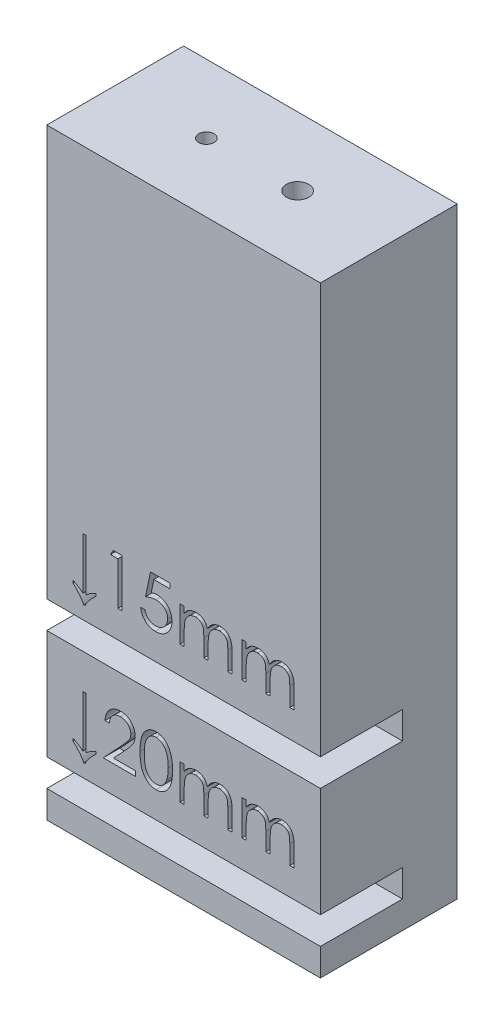
from build123d import *

# Parameters (mm, degrees)
SKETCH1_W               = 10
SKETCH1_H               = 5
BOSS_EXTRUDE1_DEPTH     = 22
SKETCH2_R               = 0.41
SKETCH2_R_2             = 0.28
CUT_EXTRUDE2_DEPTH      = 23
CUT_EXTRUDE2_DEPTH_BACK = 1
SKETCH3_W               = 10
SKETCH3_H               = 1
CUT_EXTRUDE3_DEPTH      = 3
CUT_EXTRUDE4_DEPTH      = 0.6


with BuildPart() as part:
    # Sketch1 → Boss-Extrude1 (new body)
    with BuildSketch(Plane(origin=(0, 0, 0), x_dir=(1, 0, 0), z_dir=(0, 1, 0))):
        Rectangle(SKETCH1_W, SKETCH1_H)
    extrude(amount=BOSS_EXTRUDE1_DEPTH)

    # Sketch2 → Cut-Extrude2 (cut, two sides)
    with BuildSketch(Plane(origin=(0, 0, 0), x_dir=(1, 0, 0), z_dir=(0, 1, 0))) as cut_extrude2_sk:
        with Locations((1.666666667, 0)):
            Circle(SKETCH2_R)
        with Locations((-1.666666667, 0)):
            Circle(SKETCH2_R_2)
    extrude(amount=CUT_EXTRUDE2_DEPTH, mode=Mode.SUBTRACT)
    extrude(cut_extrude2_sk.sketch, amount=-CUT_EXTRUDE2_DEPTH_BACK, mode=Mode.SUBTRACT)

    # Sketch3 → Cut-Extrude3 (cut)
    with BuildSketch(Plane.XY.offset(2.5)):
        with Locations((0, 6.5)):
            Rectangle(SKETCH3_W, SKETCH3_H)
        with Locations((0, 1.5)):
            Rectangle(SKETCH3_W, SKETCH3_H)
    extrude(amount=-CUT_EXTRUDE3_DEPTH, mode=Mode.SUBTRACT)

    # Sketch4 → Cut-Extrude4 (cut)
    with BuildSketch(Plane.XY.offset(2.5)):
        with BuildLine():
            Line((-4.038461538, 2.977213542), (-4.038461538, 3.067307692))
            add(Edge.make_bspline(
                [(-4.038461538, 3.067307692), (-4.006132303, 3.051316281), (-3.941926331, 3.019557285), (-3.849736919, 2.965774925), (-3.762023968, 2.907230434), (-3.706931473, 2.864323021), (-3.679487179, 2.842948718)],
                knots=[0, 0, 0, 0, 0.000108178, 0.000214842, 0.000319946, 0.000424275, 0.000424275, 0.000424275, 0.000424275], degree=3))
            Line((-3.679487179, 2.842948718), (-3.679487179, 4.727564103))
            Line((-3.679487179, 4.727564103), (-3.567307692, 4.727564103))
            Line((-3.567307692, 4.727564103), (-3.567307692, 2.842948718))
            add(Edge.make_bspline(
                [(-3.567307692, 2.842948718), (-3.556903118, 2.852658436), (-3.535381074, 2.872743156), (-3.499889313, 2.901252348), (-3.460721561, 2.929822277), (-3.417809068, 2.958054323), (-3.370796826, 2.985816265), (-3.32014112, 3.013355129), (-3.265630366, 3.040770457), (-3.22778201, 3.058299999), (-3.208333333, 3.067307692)],
                knots=[0, 0, 0, 0, 4.2682e-05, 8.8289e-05, 0.00013646, 0.000188089, 0.000242318, 0.000300204, 0.000361034, 0.000425331, 0.000425331, 0.000425331, 0.000425331], degree=3))
            Line((-3.208333333, 3.067307692), (-3.208333333, 2.976161859))
            add(Edge.make_bspline(
                [(-3.208333333, 2.976161859), (-3.231871552, 2.954486217), (-3.277719042, 2.912266631), (-3.341895447, 2.847679169), (-3.400124314, 2.784281697), (-3.45258414, 2.722198422), (-3.499003645, 2.661358246), (-3.539039146, 2.601413482), (-3.574014823, 2.543144471), (-3.59263083, 2.503303697), (-3.60166266, 2.483974359)],
                knots=[0, 0, 0, 0, 9.5985e-05, 0.000186959, 0.000273055, 0.000354163, 0.000430726, 0.000502481, 0.00057036, 0.000634328, 0.000634328, 0.000634328, 0.000634328], degree=3))
            Line((-3.60166266, 2.483974359), (-3.652844551, 2.483974359))
            add(Edge.make_bspline(
                [(-3.652844551, 2.483974359), (-3.660620924, 2.501989996), (-3.676857727, 2.539606039), (-3.708135379, 2.595674459), (-3.74634452, 2.653829832), (-3.790878345, 2.714679831), (-3.84303176, 2.777154909), (-3.901774183, 2.842137108), (-3.967368701, 2.909380469), (-4.014245247, 2.954107621), (-4.038461538, 2.977213542)],
                knots=[0, 0, 0, 0, 5.8838e-05, 0.000122851, 0.000192277, 0.000267511, 0.000348933, 0.000436302, 0.000530258, 0.000630666, 0.000630666, 0.000630666, 0.000630666], degree=3))
        make_face()
        with BuildLine():
            Line((-2.71474359, 4.211538462), (-2.871794872, 4.211538462))
            add(Edge.make_bspline(
                [(-2.871794872, 4.211538462), (-2.870771295, 4.232373905), (-2.868761018, 4.273294163), (-2.859346874, 4.332956116), (-2.845876435, 4.389983515), (-2.826830708, 4.443918472), (-2.803177569, 4.495237876), (-2.774812555, 4.543737884), (-2.74121563, 4.589233478), (-2.703112263, 4.6313029), (-2.661727944, 4.669896685), (-2.617074974, 4.703224307), (-2.57015246, 4.731383142), (-2.521102761, 4.754923763), (-2.469372479, 4.772593686), (-2.41543105, 4.785704506), (-2.359041482, 4.793592679), (-2.320621471, 4.794440572), (-2.301081731, 4.794871795)],
                knots=[0, 0, 0, 0, 6.2541e-05, 0.00012283, 0.000180902, 0.000238112, 0.000294107, 0.000350202, 0.000406364, 0.000463455, 0.000520264, 0.000575863, 0.000630273, 0.000684215, 0.00073876, 0.000793942, 0.00085056, 0.000909155, 0.000909155, 0.000909155, 0.000909155], degree=3))
            add(Edge.make_bspline(
                [(-2.301081731, 4.794871795), (-2.281892694, 4.794422567), (-2.244186921, 4.793539849), (-2.189155914, 4.785959335), (-2.136767267, 4.774086539), (-2.087123384, 4.757428831), (-2.040620351, 4.735036617), (-1.996908829, 4.708137848), (-1.955468424, 4.677027932), (-1.918165032, 4.640401025), (-1.883910992, 4.601299833), (-1.854359865, 4.559555881), (-1.829053283, 4.516441238), (-1.807959443, 4.471627138), (-1.792431374, 4.424691623), (-1.78064227, 4.376318022), (-1.773978563, 4.326005616), (-1.772955851, 4.291952339), (-1.772435897, 4.274639423)],
                knots=[0, 0, 0, 0, 5.7544e-05, 0.000113073, 0.000166307, 0.000218522, 0.000269796, 0.000320781, 0.000372314, 0.000424875, 0.000477311, 0.000528087, 0.000578051, 0.000627142, 0.000676363, 0.000726104, 0.000776327, 0.000828268, 0.000828268, 0.000828268, 0.000828268], degree=3))
            add(Edge.make_bspline(
                [(-1.772435897, 4.274639423), (-1.773282529, 4.250265506), (-1.774960935, 4.201945399), (-1.789318123, 4.130937968), (-1.811741378, 4.062141258), (-1.838740057, 4.006772607), (-1.865976279, 3.96215586), (-1.890520033, 3.925421508), (-1.919252438, 3.885868773), (-1.952591687, 3.843630105), (-1.989848123, 3.798374652), (-2.031359205, 3.750129755), (-2.077420946, 3.69939387), (-2.109750196, 3.664741069), (-2.126502404, 3.646784856)],
                knots=[0, 0, 0, 0, 7.3059e-05, 0.000144836, 0.00021645, 0.00028967, 0.000328989, 0.000373228, 0.000422172, 0.00047561, 0.000534634, 0.00059802, 0.000666524, 0.000740196, 0.000740196, 0.000740196, 0.000740196], degree=3))
            Line((-2.126502404, 3.646784856), (-2.564352965, 3.179487179))
            Line((-2.564352965, 3.179487179), (-1.75, 3.179487179))
            Line((-1.75, 3.179487179), (-1.75, 3))
            Line((-1.75, 3), (-2.939102564, 3))
            Line((-2.939102564, 3), (-2.260416667, 3.724258814))
            add(Edge.make_bspline(
                [(-2.260416667, 3.724258814), (-2.243892723, 3.741507967), (-2.21215361, 3.774640061), (-2.167262321, 3.823011541), (-2.126942827, 3.867886311), (-2.090934131, 3.909179585), (-2.060017378, 3.947495369), (-2.032581262, 3.981592721), (-2.010598467, 4.012969946), (-1.986740769, 4.049340253), (-1.963633778, 4.093746412), (-1.9437776, 4.148013256), (-1.931670176, 4.203876883), (-1.930217758, 4.241627901), (-1.929487179, 4.260616987)],
                knots=[0, 0, 0, 0, 7.1659e-05, 0.000137643, 0.000197965, 0.000252644, 0.000301974, 0.000345665, 0.000383891, 0.000416855, 0.000476124, 0.000533568, 0.000589809, 0.000646731, 0.000646731, 0.000646731, 0.000646731], degree=3))
            add(Edge.make_bspline(
                [(-1.929487179, 4.260616987), (-1.929805051, 4.272557686), (-1.930431514, 4.296090512), (-1.935960362, 4.330593391), (-1.944315615, 4.363875798), (-1.956288244, 4.396040108), (-1.972091614, 4.426762934), (-1.991328304, 4.456081674), (-2.013523336, 4.484426156), (-2.039198971, 4.511002805), (-2.067404731, 4.535343408), (-2.097201856, 4.556905451), (-2.128726908, 4.574925006), (-2.161846969, 4.589696755), (-2.196469703, 4.601284445), (-2.232662076, 4.609313735), (-2.270324084, 4.614354977), (-2.296040832, 4.615037063), (-2.309144631, 4.615384615)],
                knots=[0, 0, 0, 0, 3.58e-05, 7.0555e-05, 0.000104565, 0.00013862, 0.000173269, 0.000207981, 0.000243678, 0.000281116, 0.000318646, 0.000355323, 0.000391282, 0.000427375, 0.000463957, 0.000500612, 0.000538442, 0.000577744, 0.000577744, 0.000577744, 0.000577744], degree=3))
            add(Edge.make_bspline(
                [(-2.309144631, 4.615384615), (-2.322830048, 4.615027099), (-2.349705946, 4.614324997), (-2.389165462, 4.609413665), (-2.426808351, 4.600940744), (-2.462729303, 4.589352407), (-2.496989096, 4.574623133), (-2.529421118, 4.55627726), (-2.559952562, 4.534385514), (-2.588640824, 4.509565236), (-2.615072813, 4.481931435), (-2.638296251, 4.451126454), (-2.658588258, 4.417712746), (-2.676292875, 4.381780471), (-2.69067072, 4.343003581), (-2.701657295, 4.301519728), (-2.710350719, 4.257509037), (-2.713254979, 4.227116495), (-2.71474359, 4.211538462)],
                knots=[0, 0, 0, 0, 4.1053e-05, 8.0621e-05, 0.000119063, 0.000156645, 0.000193701, 0.000230747, 0.000268198, 0.000306223, 0.00034441, 0.000382691, 0.000421711, 0.000461533, 0.000502686, 0.000545547, 0.000590167, 0.000637087, 0.000637087, 0.000637087, 0.000637087], degree=3))
        make_face()
        with BuildLine():
            add(Edge.make_bspline(
                [(-1.592948718, 3.874298878), (-1.592784709, 3.902347572), (-1.592466119, 3.956832564), (-1.588921908, 4.036224885), (-1.583034237, 4.11070503), (-1.574965551, 4.180276563), (-1.565146561, 4.244957445), (-1.552038817, 4.304574824), (-1.537132416, 4.359404627), (-1.519856193, 4.409625651), (-1.500362299, 4.455914503), (-1.479145168, 4.499127103), (-1.455362771, 4.539198069), (-1.430374315, 4.576766965), (-1.403168279, 4.611218812), (-1.374518884, 4.643040143), (-1.343307945, 4.671495519), (-1.310596441, 4.69741867), (-1.276088209, 4.720143406), (-1.240766876, 4.740159775), (-1.204389323, 4.757259709), (-1.166856232, 4.770704926), (-1.128504953, 4.78181035), (-1.089201419, 4.789404824), (-1.048880737, 4.794183278), (-1.02166502, 4.794640112), (-1.00786258, 4.794871795)],
                knots=[0, 0, 0, 0, 8.4141e-05, 0.000163445, 0.000238352, 0.00030823, 0.00037353, 0.00043452, 0.000491247, 0.000543907, 0.000593714, 0.000641844, 0.000688199, 0.000733411, 0.000777102, 0.000819784, 0.000861712, 0.000903651, 0.000944876, 0.000985532, 0.001025368, 0.001065292, 0.001105018, 0.001145031, 0.001185254, 0.001226644, 0.001226644, 0.001226644, 0.001226644], degree=3))
            add(Edge.make_bspline(
                [(-1.00786258, 4.794871795), (-0.993944841, 4.794627887), (-0.966266836, 4.794142832), (-0.925346649, 4.789480861), (-0.885371808, 4.781745299), (-0.846512739, 4.770784812), (-0.808450245, 4.757186973), (-0.771482042, 4.740143415), (-0.735378501, 4.720303981), (-0.700713357, 4.696992043), (-0.667106049, 4.671000904), (-0.635382068, 4.64161957), (-0.605538525, 4.60914471), (-0.577200872, 4.573923778), (-0.551173074, 4.535281236), (-0.526386357, 4.493889181), (-0.504200339, 4.449023749), (-0.482833002, 4.401433515), (-0.464389509, 4.349801685), (-0.447756386, 4.294419305), (-0.434316902, 4.234632212), (-0.423122265, 4.170754089), (-0.414449817, 4.102550347), (-0.408133496, 4.03016719), (-0.404796954, 3.953556994), (-0.404168603, 3.90117807), (-0.403846154, 3.874298878)],
                knots=[0, 0, 0, 0, 4.174e-05, 8.3008e-05, 0.000123365, 0.000163767, 0.00020402, 0.000244493, 0.000285761, 0.000327472, 0.000369686, 0.000413101, 0.000457011, 0.000501904, 0.000548576, 0.000596673, 0.000646528, 0.000698638, 0.000753088, 0.000810875, 0.000872019, 0.0009368, 0.001005371, 0.001078211, 0.001154713, 0.001235355, 0.001235355, 0.001235355, 0.001235355], degree=3))
            add(Edge.make_bspline(
                [(-0.403846154, 3.874298878), (-0.404171946, 3.847536924), (-0.404806739, 3.795392348), (-0.408096092, 3.719126861), (-0.414575408, 3.647127839), (-0.422680402, 3.579222608), (-0.433905884, 3.515693798), (-0.447708467, 3.456321574), (-0.463033628, 3.400849538), (-0.481951025, 3.349732132), (-0.50265638, 3.302256271), (-0.525183979, 3.257922697), (-0.549318892, 3.216339551), (-0.575613264, 3.177839677), (-0.603639971, 3.142150349), (-0.633998865, 3.109901537), (-0.665834158, 3.080316201), (-0.699540366, 3.053990388), (-0.734746141, 3.030947985), (-0.77072568, 3.01034106), (-0.808117371, 2.993724712), (-0.846073848, 2.979457192), (-0.885138031, 2.968556966), (-0.925261226, 2.961020038), (-0.966239344, 2.955734114), (-0.993940127, 2.955330874), (-1.00786258, 2.955128205)],
                knots=[0, 0, 0, 0, 8.0291e-05, 0.000156443, 0.000228934, 0.000297113, 0.000361549, 0.000422351, 0.000479942, 0.000534062, 0.00058571, 0.000635252, 0.000683172, 0.000729844, 0.000775012, 0.00081916, 0.000862575, 0.000905281, 0.000947284, 0.000988723, 0.001029515, 0.001069889, 0.00111029, 0.001150991, 0.0011923, 0.00123404, 0.00123404, 0.00123404, 0.00123404], degree=3))
            add(Edge.make_bspline(
                [(-1.00786258, 2.955128205), (-1.021664637, 2.955361383), (-1.0488796, 2.955821164), (-1.089205812, 2.96057803), (-1.128347034, 2.968225781), (-1.166496411, 2.978934083), (-1.203849669, 2.992041501), (-1.239897812, 3.009118343), (-1.275041654, 3.028785378), (-1.309187432, 3.051183088), (-1.341693512, 3.07684393), (-1.372742815, 3.105226074), (-1.401555324, 3.13703778), (-1.428372372, 3.171776741), (-1.453859416, 3.209123363), (-1.477304103, 3.249587549), (-1.49898953, 3.293008854), (-1.518811275, 3.33966781), (-1.536385607, 3.390245274), (-1.551909461, 3.445319863), (-1.56416654, 3.505377681), (-1.574658018, 3.569936365), (-1.583120209, 3.63927333), (-1.588897372, 3.713426219), (-1.592468029, 3.792348823), (-1.592785564, 3.84648371), (-1.592948718, 3.874298878)],
                knots=[0, 0, 0, 0, 4.139e-05, 8.1613e-05, 0.000121626, 0.00016092, 0.000200395, 0.000240231, 0.00028041, 0.000321149, 0.000362595, 0.000404524, 0.000447206, 0.000491173, 0.000536094, 0.000582751, 0.000631352, 0.000681618, 0.000734724, 0.000791883, 0.000853143, 0.000918498, 0.000988069, 0.001062626, 0.00114158, 0.00122502, 0.00122502, 0.00122502, 0.00122502], degree=3))
        make_face()
        with BuildLine():
            add(Edge.make_bspline(
                [(-1.435897436, 3.875), (-1.435837712, 3.851625651), (-1.435721801, 3.806260628), (-1.4326937, 3.740338998), (-1.428568584, 3.678853833), (-1.423247936, 3.621727065), (-1.415346462, 3.569152059), (-1.406493068, 3.520767217), (-1.395719023, 3.476828599), (-1.382971514, 3.437034693), (-1.368451965, 3.400710159), (-1.352599034, 3.366909552), (-1.335568672, 3.335233583), (-1.316509097, 3.305966779), (-1.295751565, 3.279013697), (-1.273764936, 3.253897281), (-1.249728644, 3.23149879), (-1.216476772, 3.204635363), (-1.172578535, 3.176875796), (-1.117268308, 3.152702751), (-1.060434082, 3.137511523), (-1.021858457, 3.135579645), (-1.002604167, 3.134615385)],
                knots=[0, 0, 0, 0, 7.0116e-05, 0.000136081, 0.000197923, 0.00025499, 0.000308137, 0.000357365, 0.000402513, 0.000443754, 0.000482617, 0.000519785, 0.000555708, 0.000590421, 0.000624427, 0.000657703, 0.000690439, 0.00072285, 0.000785873, 0.00084553, 0.000903432, 0.000961133, 0.000961133, 0.000961133, 0.000961133], degree=3))
            add(Edge.make_bspline(
                [(-1.002604167, 3.134615385), (-0.983225331, 3.135414275), (-0.944507669, 3.137010406), (-0.887940772, 3.152409775), (-0.833025637, 3.175644545), (-0.789989666, 3.203118298), (-0.757248395, 3.229282462), (-0.7337899, 3.251589786), (-0.712258875, 3.27656772), (-0.691837838, 3.303517368), (-0.6731083, 3.33295361), (-0.656076731, 3.364734898), (-0.640535058, 3.398949487), (-0.631680535, 3.422834356), (-0.627153446, 3.435046074)],
                knots=[0, 0, 0, 0, 5.8022e-05, 0.000115924, 0.000174659, 0.000236419, 0.000268337, 0.000300323, 0.000333367, 0.000367161, 0.000401684, 0.000437915, 0.000475255, 0.000514317, 0.000514317, 0.000514317, 0.000514317], degree=3))
            add(Edge.make_bspline(
                [(-0.627153446, 3.435046074), (-0.621877562, 3.450660943), (-0.611165255, 3.482365826), (-0.597359368, 3.531547652), (-0.586486668, 3.583149034), (-0.576704985, 3.636861592), (-0.570028457, 3.693081442), (-0.56465455, 3.751634634), (-0.561489207, 3.812565316), (-0.561096831, 3.853962811), (-0.560897436, 3.875)],
                knots=[0, 0, 0, 0, 4.9443e-05, 0.00010039, 0.000153129, 0.000207594, 0.00026412, 0.000322899, 0.000383979, 0.000447088, 0.000447088, 0.000447088, 0.000447088], degree=3))
            add(Edge.make_bspline(
                [(-0.560897436, 3.875), (-0.561172531, 3.896033786), (-0.561710674, 3.937180369), (-0.563767668, 3.997439459), (-0.569079455, 4.054673339), (-0.574979015, 4.109128576), (-0.583677625, 4.160503727), (-0.593056529, 4.20922888), (-0.605657135, 4.254700392), (-0.619117023, 4.297630183), (-0.63452222, 4.33753051), (-0.651480087, 4.374587403), (-0.669590967, 4.408979766), (-0.689262087, 4.440613237), (-0.710259929, 4.469629508), (-0.733138703, 4.495446805), (-0.75699089, 4.518865289), (-0.790399482, 4.545596574), (-0.834136627, 4.572852422), (-0.888559451, 4.597935302), (-0.945194773, 4.612339448), (-0.9834815, 4.614370291), (-1.002604167, 4.615384615)],
                knots=[0, 0, 0, 0, 6.311e-05, 0.000123456, 0.000180808, 0.00023551, 0.000287725, 0.000337088, 0.000384284, 0.000429184, 0.000472022, 0.000512494, 0.000551386, 0.000588545, 0.000624165, 0.000658693, 0.000691913, 0.000724324, 0.000786864, 0.000846021, 0.000903497, 0.000960849, 0.000960849, 0.000960849, 0.000960849], degree=3))
            add(Edge.make_bspline(
                [(-1.002604167, 4.615384615), (-1.021959463, 4.614368892), (-1.060705316, 4.612335595), (-1.117929293, 4.597988968), (-1.172781469, 4.572982485), (-1.216402956, 4.545506299), (-1.249834849, 4.519337143), (-1.273376196, 4.496643916), (-1.295449282, 4.471820789), (-1.315783132, 4.444619832), (-1.334827774, 4.415387148), (-1.35231828, 4.383892766), (-1.368076945, 4.349977084), (-1.382619213, 4.313668866), (-1.395405607, 4.273878394), (-1.405952589, 4.229993897), (-1.415696115, 4.181762951), (-1.42259375, 4.128903197), (-1.428725627, 4.07176212), (-1.432666301, 4.010123461), (-1.43573193, 3.944091271), (-1.435841162, 3.898491692), (-1.435897436, 3.875)],
                knots=[0, 0, 0, 0, 5.805e-05, 0.000116207, 0.000175684, 0.000238224, 0.000270416, 0.000302898, 0.000336173, 0.000369967, 0.00040468, 0.000440772, 0.00047794, 0.000516803, 0.000558045, 0.000603192, 0.000652143, 0.000705587, 0.000763038, 0.000824531, 0.000890846, 0.000961312, 0.000961312, 0.000961312, 0.000961312], degree=3))
        make_face(mode=Mode.SUBTRACT)
        with BuildLine():
            Line((-0.134615385, 4.278846154), (0.022435897, 4.278846154))
            Line((0.022435897, 4.278846154), (0.022435897, 4.056590545))
            add(Edge.make_bspline(
                [(0.022435897, 4.056590545), (0.036577872, 4.076034346), (0.063675252, 4.113290532), (0.108108078, 4.162385674), (0.152496135, 4.204049752), (0.184462826, 4.225921188), (0.199819712, 4.236428285)],
                knots=[0, 0, 0, 0, 7.2076e-05, 0.000138104, 0.000198402, 0.000254151, 0.000254151, 0.000254151, 0.000254151], degree=3))
            add(Edge.make_bspline(
                [(0.199819712, 4.236428285), (0.220752043, 4.246430968), (0.262250992, 4.266261575), (0.327960605, 4.286378354), (0.39519794, 4.298740905), (0.440602047, 4.300431591), (0.463441506, 4.301282051)],
                knots=[0, 0, 0, 0, 6.9515e-05, 0.000137816, 0.000205481, 0.00027397, 0.00027397, 0.00027397, 0.00027397], degree=3))
            add(Edge.make_bspline(
                [(0.463441506, 4.301282051), (0.478888005, 4.300759406), (0.509455794, 4.299725119), (0.554747839, 4.292995101), (0.598677145, 4.281362015), (0.64098416, 4.265158353), (0.680844499, 4.245535009), (0.717389098, 4.222510155), (0.750201202, 4.196661618), (0.779264228, 4.166822151), (0.805398741, 4.132153852), (0.829438164, 4.091721727), (0.85165077, 4.044617897), (0.863961425, 4.010434626), (0.870442708, 3.992437901)],
                knots=[0, 0, 0, 0, 4.6339e-05, 9.1703e-05, 0.000137024, 0.000182404, 0.000227399, 0.000270095, 0.000311759, 0.000352415, 0.000394693, 0.000441708, 0.000493299, 0.000550659, 0.000550659, 0.000550659, 0.000550659], degree=3))
            add(Edge.make_bspline(
                [(0.870442708, 3.992437901), (0.877298334, 4.00480011), (0.890789243, 4.029127203), (0.913442061, 4.063556334), (0.937175959, 4.09575973), (0.962193206, 4.125762942), (0.988405499, 4.153417807), (1.015936199, 4.178815758), (1.04462859, 4.202065865), (1.08452471, 4.229227445), (1.136431014, 4.258078035), (1.201875071, 4.283092257), (1.269950157, 4.298550321), (1.316159006, 4.300365458), (1.339493189, 4.301282051)],
                knots=[0, 0, 0, 0, 4.2395e-05, 8.3427e-05, 0.000123532, 0.000162357, 0.000200544, 0.000237757, 0.000274657, 0.000311218, 0.00038245, 0.000452244, 0.0005208, 0.000590734, 0.000590734, 0.000590734, 0.000590734], degree=3))
            add(Edge.make_bspline(
                [(1.339493189, 4.301282051), (1.360933921, 4.300473441), (1.402895514, 4.298890912), (1.463984146, 4.286464175), (1.520955049, 4.265125352), (1.573693587, 4.236008533), (1.621273494, 4.199418942), (1.662631649, 4.155884523), (1.69751683, 4.105713211), (1.72030615, 4.058517217), (1.735763782, 4.01684955), (1.745294399, 3.981346405), (1.753714247, 3.942270628), (1.760704869, 3.899575498), (1.765814146, 3.853110193), (1.769599503, 3.802950756), (1.77216154, 3.7490582), (1.772342576, 3.71187545), (1.772435897, 3.692708333)],
                knots=[0, 0, 0, 0, 6.429e-05, 0.000125823, 0.000186055, 0.000246152, 0.000305893, 0.000365404, 0.000425599, 0.000488468, 0.000522072, 0.000558814, 0.000598626, 0.000641965, 0.000688537, 0.000738815, 0.000792857, 0.000850354, 0.000850354, 0.000850354, 0.000850354], degree=3))
            Line((1.772435897, 3.692708333), (1.772435897, 3))
            Line((1.772435897, 3), (1.615384615, 3))
            Line((1.615384615, 3), (1.615384615, 3.693409455))
            add(Edge.make_bspline(
                [(1.615384615, 3.693409455), (1.615345674, 3.709769742), (1.615270834, 3.741211726), (1.613924018, 3.786337951), (1.611386361, 3.82747213), (1.608419042, 3.864558174), (1.604297137, 3.897682568), (1.598974172, 3.926778777), (1.593335332, 3.952075683), (1.583967336, 3.980118707), (1.56899339, 4.011053812), (1.54618465, 4.0444156), (1.517449597, 4.073456), (1.484269519, 4.098665158), (1.446495296, 4.119161979), (1.404862935, 4.133799984), (1.359630909, 4.142861423), (1.328319515, 4.143764431), (1.312149439, 4.144230769)],
                knots=[0, 0, 0, 0, 4.908e-05, 9.4324e-05, 0.000135413, 0.000172706, 0.000205926, 0.000235494, 0.000261428, 0.0002836, 0.000324053, 0.000364117, 0.000404277, 0.000446064, 0.000488731, 0.000532639, 0.000578015, 0.000626473, 0.000626473, 0.000626473, 0.000626473], degree=3))
            add(Edge.make_bspline(
                [(1.312149439, 4.144230769), (1.292314462, 4.143522691), (1.253113006, 4.142123258), (1.195890263, 4.127836321), (1.140904755, 4.106296196), (1.089797188, 4.075079967), (1.042783293, 4.037675786), (1.002333504, 3.993200988), (0.968917411, 3.942886024), (0.946290423, 3.896312673), (0.931995773, 3.854477951), (0.922557315, 3.817929265), (0.915215619, 3.776388481), (0.908330355, 3.730134736), (0.903836491, 3.678849646), (0.899752304, 3.622770445), (0.897841873, 3.561728465), (0.897574644, 3.519415121), (0.897435897, 3.497445913)],
                knots=[0, 0, 0, 0, 5.9394e-05, 0.000117385, 0.000175908, 0.000235968, 0.000296301, 0.000355608, 0.000415501, 0.000476964, 0.000510334, 0.000548001, 0.00059008, 0.000636831, 0.000688247, 0.00074447, 0.000805503, 0.000871413, 0.000871413, 0.000871413, 0.000871413], degree=3))
            Line((0.897435897, 3.497445913), (0.897435897, 3))
            Line((0.897435897, 3), (0.740384615, 3))
            Line((0.740384615, 3), (0.740384615, 3.650290465))
            add(Edge.make_bspline(
                [(0.740384615, 3.650290465), (0.7403449, 3.668637124), (0.740268491, 3.703934253), (0.738930333, 3.75455109), (0.736387022, 3.80059163), (0.733446748, 3.842002362), (0.729216658, 3.878708027), (0.724411777, 3.910905406), (0.718737472, 3.938513781), (0.70934253, 3.968795474), (0.694985296, 4.002155935), (0.671891165, 4.037726446), (0.643087374, 4.068860495), (0.609301936, 4.095439869), (0.571299095, 4.117410609), (0.529307395, 4.133240485), (0.483704939, 4.14245263), (0.452266086, 4.143626878), (0.436097756, 4.144230769)],
                knots=[0, 0, 0, 0, 5.5039e-05, 0.00010589, 0.000151879, 0.000193365, 0.000230414, 0.00026269, 0.000291018, 0.000314859, 0.000357715, 0.000399526, 0.000441454, 0.000484378, 0.000528033, 0.000572633, 0.000618421, 0.000666901, 0.000666901, 0.000666901, 0.000666901], degree=3))
            add(Edge.make_bspline(
                [(0.436097756, 4.144230769), (0.417089651, 4.143465539), (0.379207171, 4.141940463), (0.323556186, 4.128213326), (0.269813344, 4.106711289), (0.218835995, 4.076881379), (0.171998921, 4.03993184), (0.130994787, 3.996474392), (0.096523524, 3.947049875), (0.073657617, 3.900967617), (0.05890838, 3.860180979), (0.049110713, 3.825505506), (0.0406909, 3.787005382), (0.034433889, 3.744561826), (0.028393681, 3.698451279), (0.025478526, 3.648444034), (0.022642745, 3.59458299), (0.022506538, 3.557396718), (0.022435897, 3.538110978)],
                knots=[0, 0, 0, 0, 5.6946e-05, 0.000113492, 0.000170908, 0.000230132, 0.000290028, 0.000349298, 0.000408718, 0.000470174, 0.000502999, 0.000538729, 0.000578198, 0.000621136, 0.0006674, 0.000717653, 0.000771345, 0.000829192, 0.000829192, 0.000829192, 0.000829192], degree=3))
            Line((0.022435897, 3.538110978), (0.022435897, 3))
            Line((0.022435897, 3), (-0.134615385, 3))
            Line((-0.134615385, 3), (-0.134615385, 4.278846154))
        make_face()
        with BuildLine():
            Line((2.131410256, 4.278846154), (2.288461538, 4.278846154))
            Line((2.288461538, 4.278846154), (2.288461538, 4.056590545))
            add(Edge.make_bspline(
                [(2.288461538, 4.056590545), (2.302603513, 4.076034346), (2.329700893, 4.113290532), (2.374133719, 4.162385674), (2.418521776, 4.204049752), (2.450488467, 4.225921188), (2.465845353, 4.236428285)],
                knots=[0, 0, 0, 0, 7.2076e-05, 0.000138104, 0.000198402, 0.000254151, 0.000254151, 0.000254151, 0.000254151], degree=3))
            add(Edge.make_bspline(
                [(2.465845353, 4.236428285), (2.486777684, 4.246430968), (2.528276634, 4.266261575), (2.593986246, 4.286378354), (2.661223581, 4.298740905), (2.706627688, 4.300431591), (2.729467147, 4.301282051)],
                knots=[0, 0, 0, 0, 6.9515e-05, 0.000137816, 0.000205481, 0.00027397, 0.00027397, 0.00027397, 0.00027397], degree=3))
            add(Edge.make_bspline(
                [(2.729467147, 4.301282051), (2.744913646, 4.300759406), (2.775481435, 4.299725119), (2.82077348, 4.292995101), (2.864702786, 4.281362015), (2.907009801, 4.265158353), (2.946870141, 4.245535009), (2.983414739, 4.222510155), (3.016226843, 4.196661618), (3.045289869, 4.166822151), (3.071424382, 4.132153852), (3.095463805, 4.091721727), (3.117676411, 4.044617897), (3.129987066, 4.010434626), (3.136468349, 3.992437901)],
                knots=[0, 0, 0, 0, 4.6339e-05, 9.1703e-05, 0.000137024, 0.000182404, 0.000227399, 0.000270095, 0.000311759, 0.000352415, 0.000394693, 0.000441708, 0.000493299, 0.000550659, 0.000550659, 0.000550659, 0.000550659], degree=3))
            add(Edge.make_bspline(
                [(3.136468349, 3.992437901), (3.143323975, 4.00480011), (3.156814884, 4.029127203), (3.179467702, 4.063556334), (3.2032016, 4.09575973), (3.228218847, 4.125762942), (3.25443114, 4.153417807), (3.28196184, 4.178815758), (3.310654231, 4.202065865), (3.350550351, 4.229227445), (3.402456655, 4.258078035), (3.467900712, 4.283092257), (3.535975798, 4.298550321), (3.582184647, 4.300365458), (3.60551883, 4.301282051)],
                knots=[0, 0, 0, 0, 4.2395e-05, 8.3427e-05, 0.000123532, 0.000162357, 0.000200544, 0.000237757, 0.000274657, 0.000311218, 0.00038245, 0.000452244, 0.0005208, 0.000590734, 0.000590734, 0.000590734, 0.000590734], degree=3))
            add(Edge.make_bspline(
                [(3.60551883, 4.301282051), (3.626959562, 4.300473441), (3.668921155, 4.298890912), (3.730009788, 4.286464175), (3.78698069, 4.265125352), (3.839719228, 4.236008533), (3.887299135, 4.199418942), (3.92865729, 4.155884523), (3.963542471, 4.105713211), (3.986331791, 4.058517217), (4.001789423, 4.01684955), (4.01132004, 3.981346405), (4.019739888, 3.942270628), (4.026730511, 3.899575498), (4.031839787, 3.853110193), (4.035625144, 3.802950756), (4.038187181, 3.7490582), (4.038368217, 3.71187545), (4.038461538, 3.692708333)],
                knots=[0, 0, 0, 0, 6.429e-05, 0.000125823, 0.000186055, 0.000246152, 0.000305893, 0.000365404, 0.000425599, 0.000488468, 0.000522072, 0.000558814, 0.000598626, 0.000641965, 0.000688537, 0.000738815, 0.000792857, 0.000850354, 0.000850354, 0.000850354, 0.000850354], degree=3))
            Line((4.038461538, 3.692708333), (4.038461538, 3))
            Line((4.038461538, 3), (3.881410256, 3))
            Line((3.881410256, 3), (3.881410256, 3.693409455))
            add(Edge.make_bspline(
                [(3.881410256, 3.693409455), (3.881371315, 3.709769742), (3.881296475, 3.741211726), (3.87994966, 3.786337951), (3.877412002, 3.82747213), (3.874444683, 3.864558174), (3.870322778, 3.897682568), (3.864999813, 3.926778777), (3.859360973, 3.952075683), (3.849992977, 3.980118707), (3.835019031, 4.011053812), (3.812210291, 4.0444156), (3.783475238, 4.073456), (3.75029516, 4.098665158), (3.712520937, 4.119161979), (3.670888576, 4.133799984), (3.62565655, 4.142861423), (3.594345156, 4.143764431), (3.57817508, 4.144230769)],
                knots=[0, 0, 0, 0, 4.908e-05, 9.4324e-05, 0.000135413, 0.000172706, 0.000205926, 0.000235494, 0.000261428, 0.0002836, 0.000324053, 0.000364117, 0.000404277, 0.000446064, 0.000488731, 0.000532639, 0.000578015, 0.000626473, 0.000626473, 0.000626473, 0.000626473], degree=3))
            add(Edge.make_bspline(
                [(3.57817508, 4.144230769), (3.558340103, 4.143522691), (3.519138647, 4.142123258), (3.461915904, 4.127836321), (3.406930396, 4.106296196), (3.355822829, 4.075079967), (3.308808934, 4.037675786), (3.268359145, 3.993200988), (3.234943052, 3.942886024), (3.212316064, 3.896312673), (3.198021414, 3.854477951), (3.188582956, 3.817929265), (3.18124126, 3.776388481), (3.174355996, 3.730134736), (3.169862132, 3.678849646), (3.165777945, 3.622770445), (3.163867514, 3.561728465), (3.163600285, 3.519415121), (3.163461538, 3.497445913)],
                knots=[0, 0, 0, 0, 5.9394e-05, 0.000117385, 0.000175908, 0.000235968, 0.000296301, 0.000355608, 0.000415501, 0.000476964, 0.000510334, 0.000548001, 0.00059008, 0.000636831, 0.000688247, 0.00074447, 0.000805503, 0.000871413, 0.000871413, 0.000871413, 0.000871413], degree=3))
            Line((3.163461538, 3.497445913), (3.163461538, 3))
            Line((3.163461538, 3), (3.006410256, 3))
            Line((3.006410256, 3), (3.006410256, 3.650290465))
            add(Edge.make_bspline(
                [(3.006410256, 3.650290465), (3.006370541, 3.668637124), (3.006294132, 3.703934253), (3.004955974, 3.75455109), (3.002412663, 3.80059163), (2.999472389, 3.842002362), (2.995242299, 3.878708027), (2.990437418, 3.910905406), (2.984763113, 3.938513781), (2.975368171, 3.968795474), (2.961010937, 4.002155935), (2.937916806, 4.037726446), (2.909113015, 4.068860495), (2.875327577, 4.095439869), (2.837324736, 4.117410609), (2.795333036, 4.133240485), (2.74973058, 4.14245263), (2.718291727, 4.143626878), (2.702123397, 4.144230769)],
                knots=[0, 0, 0, 0, 5.5039e-05, 0.00010589, 0.000151879, 0.000193365, 0.000230414, 0.00026269, 0.000291018, 0.000314859, 0.000357715, 0.000399526, 0.000441454, 0.000484378, 0.000528033, 0.000572633, 0.000618421, 0.000666901, 0.000666901, 0.000666901, 0.000666901], degree=3))
            add(Edge.make_bspline(
                [(2.702123397, 4.144230769), (2.683115292, 4.143465539), (2.645232812, 4.141940463), (2.589581827, 4.128213326), (2.535838985, 4.106711289), (2.484861636, 4.076881379), (2.438024562, 4.03993184), (2.397020428, 3.996474392), (2.362549165, 3.947049875), (2.339683258, 3.900967617), (2.324934021, 3.860180979), (2.315136354, 3.825505506), (2.306716541, 3.787005382), (2.30045953, 3.744561826), (2.294419322, 3.698451279), (2.291504167, 3.648444034), (2.288668386, 3.59458299), (2.288532179, 3.557396718), (2.288461538, 3.538110978)],
                knots=[0, 0, 0, 0, 5.6946e-05, 0.000113492, 0.000170908, 0.000230132, 0.000290028, 0.000349298, 0.000408718, 0.000470174, 0.000502999, 0.000538729, 0.000578198, 0.000621136, 0.0006674, 0.000717653, 0.000771345, 0.000829192, 0.000829192, 0.000829192, 0.000829192], degree=3))
            Line((2.288461538, 3.538110978), (2.288461538, 3))
            Line((2.288461538, 3), (2.131410256, 3))
            Line((2.131410256, 3), (2.131410256, 4.278846154))
        make_face()
        with BuildLine():
            Line((-4.038461538, 7.977213542), (-4.038461538, 8.067307692))
            add(Edge.make_bspline(
                [(-4.038461538, 8.067307692), (-4.006132303, 8.051316281), (-3.941926331, 8.019557285), (-3.849736919, 7.965774925), (-3.762023968, 7.907230434), (-3.706931473, 7.864323021), (-3.679487179, 7.842948718)],
                knots=[0, 0, 0, 0, 0.000108178, 0.000214842, 0.000319946, 0.000424275, 0.000424275, 0.000424275, 0.000424275], degree=3))
            Line((-3.679487179, 7.842948718), (-3.679487179, 9.727564103))
            Line((-3.679487179, 9.727564103), (-3.567307692, 9.727564103))
            Line((-3.567307692, 9.727564103), (-3.567307692, 7.842948718))
            add(Edge.make_bspline(
                [(-3.567307692, 7.842948718), (-3.556903118, 7.852658436), (-3.535381074, 7.872743156), (-3.499889313, 7.901252348), (-3.460721561, 7.929822277), (-3.417809068, 7.958054323), (-3.370796826, 7.985816265), (-3.32014112, 8.013355129), (-3.265630366, 8.040770457), (-3.22778201, 8.058299999), (-3.208333333, 8.067307692)],
                knots=[0, 0, 0, 0, 4.2682e-05, 8.8289e-05, 0.00013646, 0.000188089, 0.000242318, 0.000300204, 0.000361034, 0.000425331, 0.000425331, 0.000425331, 0.000425331], degree=3))
            Line((-3.208333333, 8.067307692), (-3.208333333, 7.976161859))
            add(Edge.make_bspline(
                [(-3.208333333, 7.976161859), (-3.231871552, 7.954486217), (-3.277719042, 7.912266631), (-3.341895447, 7.847679169), (-3.400124314, 7.784281697), (-3.45258414, 7.722198422), (-3.499003645, 7.661358246), (-3.539039146, 7.601413482), (-3.574014823, 7.543144471), (-3.59263083, 7.503303697), (-3.60166266, 7.483974359)],
                knots=[0, 0, 0, 0, 9.5985e-05, 0.000186959, 0.000273055, 0.000354163, 0.000430726, 0.000502481, 0.00057036, 0.000634328, 0.000634328, 0.000634328, 0.000634328], degree=3))
            Line((-3.60166266, 7.483974359), (-3.652844551, 7.483974359))
            add(Edge.make_bspline(
                [(-3.652844551, 7.483974359), (-3.660620924, 7.501989996), (-3.676857727, 7.539606039), (-3.708135379, 7.595674459), (-3.74634452, 7.653829832), (-3.790878345, 7.714679831), (-3.84303176, 7.777154909), (-3.901774183, 7.842137108), (-3.967368701, 7.909380469), (-4.014245247, 7.954107621), (-4.038461538, 7.977213542)],
                knots=[0, 0, 0, 0, 5.8838e-05, 0.000122851, 0.000192277, 0.000267511, 0.000348933, 0.000436302, 0.000530258, 0.000630666, 0.000630666, 0.000630666, 0.000630666], degree=3))
        make_face()
        Polygon((-2.567157452, 9.75), (-2.243589744, 9.75), (-2.243589744, 8), (-2.400641026, 8), (-2.400641026, 9.570512821), (-2.669871795, 9.570512821), align=None)
        with BuildLine():
            Line((-0.493589744, 9.75), (-0.493589744, 9.570512821))
            Line((-0.493589744, 9.570512821), (-1.088842147, 9.570512821))
            Line((-1.088842147, 9.570512821), (-1.183143029, 9.110226362))
            add(Edge.make_bspline(
                [(-1.183143029, 9.110226362), (-1.164615092, 9.115341498), (-1.128720144, 9.125251265), (-1.075740213, 9.13625415), (-1.025444112, 9.142886872), (-0.992806426, 9.143792527), (-0.977013221, 9.144230769)],
                knots=[0, 0, 0, 0, 5.7651e-05, 0.00011169, 0.000162216, 0.000209588, 0.000209588, 0.000209588, 0.000209588], degree=3))
            add(Edge.make_bspline(
                [(-0.977013221, 9.144230769), (-0.957471351, 9.143807801), (-0.919047153, 9.142976141), (-0.862827679, 9.134990216), (-0.809161233, 9.122420259), (-0.758160047, 9.104859998), (-0.709729772, 9.082405131), (-0.664315991, 9.054355161), (-0.621237035, 9.021588496), (-0.581265738, 8.98391599), (-0.545003584, 8.942455181), (-0.513120589, 8.897876246), (-0.486039294, 8.850612415), (-0.464258916, 8.80021211), (-0.446866749, 8.747232534), (-0.435290752, 8.691116242), (-0.427582397, 8.632392182), (-0.426721204, 8.592239897), (-0.426282051, 8.571764824)],
                knots=[0, 0, 0, 0, 5.8595e-05, 0.000115213, 0.000169972, 0.00022374, 0.000276749, 0.000329778, 0.000383556, 0.000438861, 0.000494264, 0.000548546, 0.000603028, 0.000657346, 0.000712998, 0.000769997, 0.000829002, 0.000890399, 0.000890399, 0.000890399, 0.000890399], degree=3))
            add(Edge.make_bspline(
                [(-0.426282051, 8.571764824), (-0.426614589, 8.557503714), (-0.42727517, 8.52917422), (-0.430634464, 8.487102119), (-0.437102322, 8.445920703), (-0.445786184, 8.405624507), (-0.457057393, 8.366289821), (-0.47070192, 8.327804057), (-0.487399934, 8.290406754), (-0.505715621, 8.253744056), (-0.52633886, 8.218644802), (-0.549228114, 8.185820309), (-0.57341086, 8.154778168), (-0.599431552, 8.125851302), (-0.62753205, 8.099229793), (-0.657372033, 8.074755652), (-0.688713393, 8.052014987), (-0.722041014, 8.031930889), (-0.756612256, 8.013449411), (-0.792926364, 7.998287643), (-0.830156714, 7.984732379), (-0.868839152, 7.973927615), (-0.908886059, 7.965461338), (-0.950363446, 7.959711037), (-0.993053781, 7.955522819), (-1.021991288, 7.95526064), (-1.036608574, 7.955128205)],
                knots=[0, 0, 0, 0, 4.2791e-05, 8.5005e-05, 0.000126503, 0.000167759, 0.000208593, 0.000249176, 0.000290145, 0.000331378, 0.00037208, 0.000412144, 0.000451346, 0.000490067, 0.000528749, 0.000567351, 0.00060578, 0.000644799, 0.000684001, 0.000723266, 0.000762741, 0.000802804, 0.000843644, 0.000885438, 0.00092838, 0.000972212, 0.000972212, 0.000972212, 0.000972212], degree=3))
            add(Edge.make_bspline(
                [(-1.036608574, 7.955128205), (-1.054045664, 7.955473624), (-1.088351079, 7.956153195), (-1.138611363, 7.963262438), (-1.186968666, 7.973444396), (-1.233033716, 7.988762531), (-1.277219348, 8.007956178), (-1.318930707, 8.032214264), (-1.359233595, 8.059703816), (-1.396489614, 8.092143992), (-1.43106767, 8.127601833), (-1.462020925, 8.166080654), (-1.489587713, 8.206945375), (-1.513326587, 8.250394452), (-1.533575597, 8.296313718), (-1.549483091, 8.344875218), (-1.562322269, 8.39582522), (-1.567753979, 8.430901975), (-1.570512821, 8.448717949)],
                knots=[0, 0, 0, 0, 5.2276e-05, 0.000102847, 0.000152012, 0.000200346, 0.00024822, 0.000296267, 0.000344889, 0.000394358, 0.000444188, 0.000493298, 0.000542302, 0.000591878, 0.000641639, 0.000692634, 0.000745008, 0.000799067, 0.000799067, 0.000799067, 0.000799067], degree=3))
            Line((-1.570512821, 8.448717949), (-1.413461538, 8.448717949))
            add(Edge.make_bspline(
                [(-1.413461538, 8.448717949), (-1.40959726, 8.432029722), (-1.402169902, 8.399954025), (-1.385867027, 8.354888354), (-1.365934089, 8.314728743), (-1.342231915, 8.278943951), (-1.3139569, 8.247739452), (-1.281692186, 8.219930921), (-1.245518324, 8.194843357), (-1.205321709, 8.173931973), (-1.162915169, 8.156097596), (-1.118531564, 8.144221749), (-1.073379391, 8.135871302), (-1.042840206, 8.135035422), (-1.02749399, 8.134615385)],
                knots=[0, 0, 0, 0, 5.1354e-05, 9.8706e-05, 0.000143387, 0.000185584, 0.000227041, 0.000269286, 0.000313141, 0.000358776, 0.000404997, 0.00045084, 0.00049637, 0.000542359, 0.000542359, 0.000542359, 0.000542359], degree=3))
            add(Edge.make_bspline(
                [(-1.02749399, 8.134615385), (-1.012514768, 8.135025774), (-0.983020557, 8.135833833), (-0.939614864, 8.142053339), (-0.897708427, 8.151632124), (-0.857714748, 8.165967052), (-0.818933978, 8.183389411), (-0.782347093, 8.205746949), (-0.746895655, 8.231476958), (-0.713681588, 8.260955273), (-0.683261863, 8.293440121), (-0.656383803, 8.328178817), (-0.633995346, 8.365237241), (-0.615128292, 8.403973817), (-0.600801642, 8.444813096), (-0.590581152, 8.487563683), (-0.584579622, 8.532331173), (-0.583754032, 8.562865828), (-0.583333333, 8.578425481)],
                knots=[0, 0, 0, 0, 4.4921e-05, 8.845e-05, 0.000131306, 0.000173659, 0.000215698, 0.000258624, 0.000302027, 0.000346977, 0.000391621, 0.000435374, 0.000478481, 0.000521286, 0.000564416, 0.000608035, 0.000652954, 0.000699626, 0.000699626, 0.000699626, 0.000699626], degree=3))
            add(Edge.make_bspline(
                [(-0.583333333, 8.578425481), (-0.583662573, 8.592463357), (-0.584307013, 8.619940501), (-0.589572298, 8.660140104), (-0.598730784, 8.698176625), (-0.611442724, 8.734233742), (-0.627582478, 8.768345464), (-0.647305634, 8.800546994), (-0.670982333, 8.83041391), (-0.698028278, 8.857960187), (-0.727657298, 8.883382625), (-0.760379169, 8.905054668), (-0.795509133, 8.923286627), (-0.832623932, 8.939020626), (-0.872606382, 8.950320999), (-0.914664698, 8.958804941), (-0.959253052, 8.963712623), (-0.989738396, 8.964393567), (-1.005408654, 8.96474359)],
                knots=[0, 0, 0, 0, 4.2104e-05, 8.2412e-05, 0.000121354, 0.000159273, 0.000196908, 0.000234365, 0.000272307, 0.00031098, 0.000350031, 0.000389214, 0.000428416, 0.000468649, 0.000509917, 0.000552818, 0.00059726, 0.000644268, 0.000644268, 0.000644268, 0.000644268], degree=3))
            add(Edge.make_bspline(
                [(-1.005408654, 8.96474359), (-1.018973118, 8.964453294), (-1.046980296, 8.963853907), (-1.089941709, 8.959440659), (-1.135087571, 8.952321012), (-1.182244819, 8.942527888), (-1.231555073, 8.92971235), (-1.282914273, 8.914355099), (-1.336430406, 8.8959941), (-1.372489268, 8.882127993), (-1.391025641, 8.875)],
                knots=[0, 0, 0, 0, 4.0689e-05, 8.4013e-05, 0.000129429, 0.000177762, 0.000228437, 0.000282229, 0.000338546, 0.000398122, 0.000398122, 0.000398122, 0.000398122], degree=3))
            Line((-1.391025641, 8.875), (-1.211538462, 9.75))
            Line((-1.211538462, 9.75), (-0.493589744, 9.75))
        make_face()
        with BuildLine():
            Line((-0.134615385, 9.278846154), (0.022435897, 9.278846154))
            Line((0.022435897, 9.278846154), (0.022435897, 9.056590545))
            add(Edge.make_bspline(
                [(0.022435897, 9.056590545), (0.036577872, 9.076034346), (0.063675252, 9.113290532), (0.108108078, 9.162385674), (0.152496135, 9.204049752), (0.184462826, 9.225921188), (0.199819712, 9.236428285)],
                knots=[0, 0, 0, 0, 7.2076e-05, 0.000138104, 0.000198402, 0.000254151, 0.000254151, 0.000254151, 0.000254151], degree=3))
            add(Edge.make_bspline(
                [(0.199819712, 9.236428285), (0.220752043, 9.246430968), (0.262250992, 9.266261575), (0.327960605, 9.286378354), (0.39519794, 9.298740905), (0.440602047, 9.300431591), (0.463441506, 9.301282051)],
                knots=[0, 0, 0, 0, 6.9515e-05, 0.000137816, 0.000205481, 0.00027397, 0.00027397, 0.00027397, 0.00027397], degree=3))
            add(Edge.make_bspline(
                [(0.463441506, 9.301282051), (0.478888005, 9.300759406), (0.509455794, 9.299725119), (0.554747839, 9.292995101), (0.598677145, 9.281362015), (0.64098416, 9.265158353), (0.680844499, 9.245535009), (0.717389098, 9.222510155), (0.750201202, 9.196661618), (0.779264228, 9.166822151), (0.805398741, 9.132153852), (0.829438164, 9.091721727), (0.85165077, 9.044617897), (0.863961425, 9.010434626), (0.870442708, 8.992437901)],
                knots=[0, 0, 0, 0, 4.6339e-05, 9.1703e-05, 0.000137024, 0.000182404, 0.000227399, 0.000270095, 0.000311759, 0.000352415, 0.000394693, 0.000441708, 0.000493299, 0.000550659, 0.000550659, 0.000550659, 0.000550659], degree=3))
            add(Edge.make_bspline(
                [(0.870442708, 8.992437901), (0.877298334, 9.00480011), (0.890789243, 9.029127203), (0.913442061, 9.063556334), (0.937175959, 9.09575973), (0.962193206, 9.125762942), (0.988405499, 9.153417807), (1.015936199, 9.178815758), (1.04462859, 9.202065865), (1.08452471, 9.229227445), (1.136431014, 9.258078035), (1.201875071, 9.283092257), (1.269950157, 9.298550321), (1.316159006, 9.300365458), (1.339493189, 9.301282051)],
                knots=[0, 0, 0, 0, 4.2395e-05, 8.3427e-05, 0.000123532, 0.000162357, 0.000200544, 0.000237757, 0.000274657, 0.000311218, 0.00038245, 0.000452244, 0.0005208, 0.000590734, 0.000590734, 0.000590734, 0.000590734], degree=3))
            add(Edge.make_bspline(
                [(1.339493189, 9.301282051), (1.360933921, 9.300473441), (1.402895514, 9.298890912), (1.463984146, 9.286464175), (1.520955049, 9.265125352), (1.573693587, 9.236008533), (1.621273494, 9.199418942), (1.662631649, 9.155884523), (1.69751683, 9.105713211), (1.72030615, 9.058517217), (1.735763782, 9.01684955), (1.745294399, 8.981346405), (1.753714247, 8.942270628), (1.760704869, 8.899575498), (1.765814146, 8.853110193), (1.769599503, 8.802950756), (1.77216154, 8.7490582), (1.772342576, 8.71187545), (1.772435897, 8.692708333)],
                knots=[0, 0, 0, 0, 6.429e-05, 0.000125823, 0.000186055, 0.000246152, 0.000305893, 0.000365404, 0.000425599, 0.000488468, 0.000522072, 0.000558814, 0.000598626, 0.000641965, 0.000688537, 0.000738815, 0.000792857, 0.000850354, 0.000850354, 0.000850354, 0.000850354], degree=3))
            Line((1.772435897, 8.692708333), (1.772435897, 8))
            Line((1.772435897, 8), (1.615384615, 8))
            Line((1.615384615, 8), (1.615384615, 8.693409455))
            add(Edge.make_bspline(
                [(1.615384615, 8.693409455), (1.615345674, 8.709769742), (1.615270834, 8.741211726), (1.613924018, 8.786337951), (1.611386361, 8.82747213), (1.608419042, 8.864558174), (1.604297137, 8.897682568), (1.598974172, 8.926778777), (1.593335332, 8.952075683), (1.583967336, 8.980118707), (1.56899339, 9.011053812), (1.54618465, 9.0444156), (1.517449597, 9.073456), (1.484269519, 9.098665158), (1.446495296, 9.119161979), (1.404862935, 9.133799984), (1.359630909, 9.142861423), (1.328319515, 9.143764431), (1.312149439, 9.144230769)],
                knots=[0, 0, 0, 0, 4.908e-05, 9.4324e-05, 0.000135413, 0.000172706, 0.000205926, 0.000235494, 0.000261428, 0.0002836, 0.000324053, 0.000364117, 0.000404277, 0.000446064, 0.000488731, 0.000532639, 0.000578015, 0.000626473, 0.000626473, 0.000626473, 0.000626473], degree=3))
            add(Edge.make_bspline(
                [(1.312149439, 9.144230769), (1.292314462, 9.143522691), (1.253113006, 9.142123258), (1.195890263, 9.127836321), (1.140904755, 9.106296196), (1.089797188, 9.075079967), (1.042783293, 9.037675786), (1.002333504, 8.993200988), (0.968917411, 8.942886024), (0.946290423, 8.896312673), (0.931995773, 8.854477951), (0.922557315, 8.817929265), (0.915215619, 8.776388481), (0.908330355, 8.730134736), (0.903836491, 8.678849646), (0.899752304, 8.622770445), (0.897841873, 8.561728465), (0.897574644, 8.519415121), (0.897435897, 8.497445913)],
                knots=[0, 0, 0, 0, 5.9394e-05, 0.000117385, 0.000175908, 0.000235968, 0.000296301, 0.000355608, 0.000415501, 0.000476964, 0.000510334, 0.000548001, 0.00059008, 0.000636831, 0.000688247, 0.00074447, 0.000805503, 0.000871413, 0.000871413, 0.000871413, 0.000871413], degree=3))
            Line((0.897435897, 8.497445913), (0.897435897, 8))
            Line((0.897435897, 8), (0.740384615, 8))
            Line((0.740384615, 8), (0.740384615, 8.650290465))
            add(Edge.make_bspline(
                [(0.740384615, 8.650290465), (0.7403449, 8.668637124), (0.740268491, 8.703934253), (0.738930333, 8.75455109), (0.736387022, 8.80059163), (0.733446748, 8.842002362), (0.729216658, 8.878708027), (0.724411777, 8.910905406), (0.718737472, 8.938513781), (0.70934253, 8.968795474), (0.694985296, 9.002155935), (0.671891165, 9.037726446), (0.643087374, 9.068860495), (0.609301936, 9.095439869), (0.571299095, 9.117410609), (0.529307395, 9.133240485), (0.483704939, 9.14245263), (0.452266086, 9.143626878), (0.436097756, 9.144230769)],
                knots=[0, 0, 0, 0, 5.5039e-05, 0.00010589, 0.000151879, 0.000193365, 0.000230414, 0.00026269, 0.000291018, 0.000314859, 0.000357715, 0.000399526, 0.000441454, 0.000484378, 0.000528033, 0.000572633, 0.000618421, 0.000666901, 0.000666901, 0.000666901, 0.000666901], degree=3))
            add(Edge.make_bspline(
                [(0.436097756, 9.144230769), (0.417089651, 9.143465539), (0.379207171, 9.141940463), (0.323556186, 9.128213326), (0.269813344, 9.106711289), (0.218835995, 9.076881379), (0.171998921, 9.03993184), (0.130994787, 8.996474392), (0.096523524, 8.947049875), (0.073657617, 8.900967617), (0.05890838, 8.860180979), (0.049110713, 8.825505506), (0.0406909, 8.787005382), (0.034433889, 8.744561826), (0.028393681, 8.698451279), (0.025478526, 8.648444034), (0.022642745, 8.59458299), (0.022506538, 8.557396718), (0.022435897, 8.538110978)],
                knots=[0, 0, 0, 0, 5.6946e-05, 0.000113492, 0.000170908, 0.000230132, 0.000290028, 0.000349298, 0.000408718, 0.000470174, 0.000502999, 0.000538729, 0.000578198, 0.000621136, 0.0006674, 0.000717653, 0.000771345, 0.000829192, 0.000829192, 0.000829192, 0.000829192], degree=3))
            Line((0.022435897, 8.538110978), (0.022435897, 8))
            Line((0.022435897, 8), (-0.134615385, 8))
            Line((-0.134615385, 8), (-0.134615385, 9.278846154))
        make_face()
        with BuildLine():
            Line((2.131410256, 9.278846154), (2.288461538, 9.278846154))
            Line((2.288461538, 9.278846154), (2.288461538, 9.056590545))
            add(Edge.make_bspline(
                [(2.288461538, 9.056590545), (2.302603513, 9.076034346), (2.329700893, 9.113290532), (2.374133719, 9.162385674), (2.418521776, 9.204049752), (2.450488467, 9.225921188), (2.465845353, 9.236428285)],
                knots=[0, 0, 0, 0, 7.2076e-05, 0.000138104, 0.000198402, 0.000254151, 0.000254151, 0.000254151, 0.000254151], degree=3))
            add(Edge.make_bspline(
                [(2.465845353, 9.236428285), (2.486777684, 9.246430968), (2.528276634, 9.266261575), (2.593986246, 9.286378354), (2.661223581, 9.298740905), (2.706627688, 9.300431591), (2.729467147, 9.301282051)],
                knots=[0, 0, 0, 0, 6.9515e-05, 0.000137816, 0.000205481, 0.00027397, 0.00027397, 0.00027397, 0.00027397], degree=3))
            add(Edge.make_bspline(
                [(2.729467147, 9.301282051), (2.744913646, 9.300759406), (2.775481435, 9.299725119), (2.82077348, 9.292995101), (2.864702786, 9.281362015), (2.907009801, 9.265158353), (2.946870141, 9.245535009), (2.983414739, 9.222510155), (3.016226843, 9.196661618), (3.045289869, 9.166822151), (3.071424382, 9.132153852), (3.095463805, 9.091721727), (3.117676411, 9.044617897), (3.129987066, 9.010434626), (3.136468349, 8.992437901)],
                knots=[0, 0, 0, 0, 4.6339e-05, 9.1703e-05, 0.000137024, 0.000182404, 0.000227399, 0.000270095, 0.000311759, 0.000352415, 0.000394693, 0.000441708, 0.000493299, 0.000550659, 0.000550659, 0.000550659, 0.000550659], degree=3))
            add(Edge.make_bspline(
                [(3.136468349, 8.992437901), (3.143323975, 9.00480011), (3.156814884, 9.029127203), (3.179467702, 9.063556334), (3.2032016, 9.09575973), (3.228218847, 9.125762942), (3.25443114, 9.153417807), (3.28196184, 9.178815758), (3.310654231, 9.202065865), (3.350550351, 9.229227445), (3.402456655, 9.258078035), (3.467900712, 9.283092257), (3.535975798, 9.298550321), (3.582184647, 9.300365458), (3.60551883, 9.301282051)],
                knots=[0, 0, 0, 0, 4.2395e-05, 8.3427e-05, 0.000123532, 0.000162357, 0.000200544, 0.000237757, 0.000274657, 0.000311218, 0.00038245, 0.000452244, 0.0005208, 0.000590734, 0.000590734, 0.000590734, 0.000590734], degree=3))
            add(Edge.make_bspline(
                [(3.60551883, 9.301282051), (3.626959562, 9.300473441), (3.668921155, 9.298890912), (3.730009788, 9.286464175), (3.78698069, 9.265125352), (3.839719228, 9.236008533), (3.887299135, 9.199418942), (3.92865729, 9.155884523), (3.963542471, 9.105713211), (3.986331791, 9.058517217), (4.001789423, 9.01684955), (4.01132004, 8.981346405), (4.019739888, 8.942270628), (4.026730511, 8.899575498), (4.031839787, 8.853110193), (4.035625144, 8.802950756), (4.038187181, 8.7490582), (4.038368217, 8.71187545), (4.038461538, 8.692708333)],
                knots=[0, 0, 0, 0, 6.429e-05, 0.000125823, 0.000186055, 0.000246152, 0.000305893, 0.000365404, 0.000425599, 0.000488468, 0.000522072, 0.000558814, 0.000598626, 0.000641965, 0.000688537, 0.000738815, 0.000792857, 0.000850354, 0.000850354, 0.000850354, 0.000850354], degree=3))
            Line((4.038461538, 8.692708333), (4.038461538, 8))
            Line((4.038461538, 8), (3.881410256, 8))
            Line((3.881410256, 8), (3.881410256, 8.693409455))
            add(Edge.make_bspline(
                [(3.881410256, 8.693409455), (3.881371315, 8.709769742), (3.881296475, 8.741211726), (3.87994966, 8.786337951), (3.877412002, 8.82747213), (3.874444683, 8.864558174), (3.870322778, 8.897682568), (3.864999813, 8.926778777), (3.859360973, 8.952075683), (3.849992977, 8.980118707), (3.835019031, 9.011053812), (3.812210291, 9.0444156), (3.783475238, 9.073456), (3.75029516, 9.098665158), (3.712520937, 9.119161979), (3.670888576, 9.133799984), (3.62565655, 9.142861423), (3.594345156, 9.143764431), (3.57817508, 9.144230769)],
                knots=[0, 0, 0, 0, 4.908e-05, 9.4324e-05, 0.000135413, 0.000172706, 0.000205926, 0.000235494, 0.000261428, 0.0002836, 0.000324053, 0.000364117, 0.000404277, 0.000446064, 0.000488731, 0.000532639, 0.000578015, 0.000626473, 0.000626473, 0.000626473, 0.000626473], degree=3))
            add(Edge.make_bspline(
                [(3.57817508, 9.144230769), (3.558340103, 9.143522691), (3.519138647, 9.142123258), (3.461915904, 9.127836321), (3.406930396, 9.106296196), (3.355822829, 9.075079967), (3.308808934, 9.037675786), (3.268359145, 8.993200988), (3.234943052, 8.942886024), (3.212316064, 8.896312673), (3.198021414, 8.854477951), (3.188582956, 8.817929265), (3.18124126, 8.776388481), (3.174355996, 8.730134736), (3.169862132, 8.678849646), (3.165777945, 8.622770445), (3.163867514, 8.561728465), (3.163600285, 8.519415121), (3.163461538, 8.497445913)],
                knots=[0, 0, 0, 0, 5.9394e-05, 0.000117385, 0.000175908, 0.000235968, 0.000296301, 0.000355608, 0.000415501, 0.000476964, 0.000510334, 0.000548001, 0.00059008, 0.000636831, 0.000688247, 0.00074447, 0.000805503, 0.000871413, 0.000871413, 0.000871413, 0.000871413], degree=3))
            Line((3.163461538, 8.497445913), (3.163461538, 8))
            Line((3.163461538, 8), (3.006410256, 8))
            Line((3.006410256, 8), (3.006410256, 8.650290465))
            add(Edge.make_bspline(
                [(3.006410256, 8.650290465), (3.006370541, 8.668637124), (3.006294132, 8.703934253), (3.004955974, 8.75455109), (3.002412663, 8.80059163), (2.999472389, 8.842002362), (2.995242299, 8.878708027), (2.990437418, 8.910905406), (2.984763113, 8.938513781), (2.975368171, 8.968795474), (2.961010937, 9.002155935), (2.937916806, 9.037726446), (2.909113015, 9.068860495), (2.875327577, 9.095439869), (2.837324736, 9.117410609), (2.795333036, 9.133240485), (2.74973058, 9.14245263), (2.718291727, 9.143626878), (2.702123397, 9.144230769)],
                knots=[0, 0, 0, 0, 5.5039e-05, 0.00010589, 0.000151879, 0.000193365, 0.000230414, 0.00026269, 0.000291018, 0.000314859, 0.000357715, 0.000399526, 0.000441454, 0.000484378, 0.000528033, 0.000572633, 0.000618421, 0.000666901, 0.000666901, 0.000666901, 0.000666901], degree=3))
            add(Edge.make_bspline(
                [(2.702123397, 9.144230769), (2.683115292, 9.143465539), (2.645232812, 9.141940463), (2.589581827, 9.128213326), (2.535838985, 9.106711289), (2.484861636, 9.076881379), (2.438024562, 9.03993184), (2.397020428, 8.996474392), (2.362549165, 8.947049875), (2.339683258, 8.900967617), (2.324934021, 8.860180979), (2.315136354, 8.825505506), (2.306716541, 8.787005382), (2.30045953, 8.744561826), (2.294419322, 8.698451279), (2.291504167, 8.648444034), (2.288668386, 8.59458299), (2.288532179, 8.557396718), (2.288461538, 8.538110978)],
                knots=[0, 0, 0, 0, 5.6946e-05, 0.000113492, 0.000170908, 0.000230132, 0.000290028, 0.000349298, 0.000408718, 0.000470174, 0.000502999, 0.000538729, 0.000578198, 0.000621136, 0.0006674, 0.000717653, 0.000771345, 0.000829192, 0.000829192, 0.000829192, 0.000829192], degree=3))
            Line((2.288461538, 8.538110978), (2.288461538, 8))
            Line((2.288461538, 8), (2.131410256, 8))
            Line((2.131410256, 8), (2.131410256, 9.278846154))
        make_face()
    extrude(amount=-CUT_EXTRUDE4_DEPTH, mode=Mode.SUBTRACT)


solid = part.part
